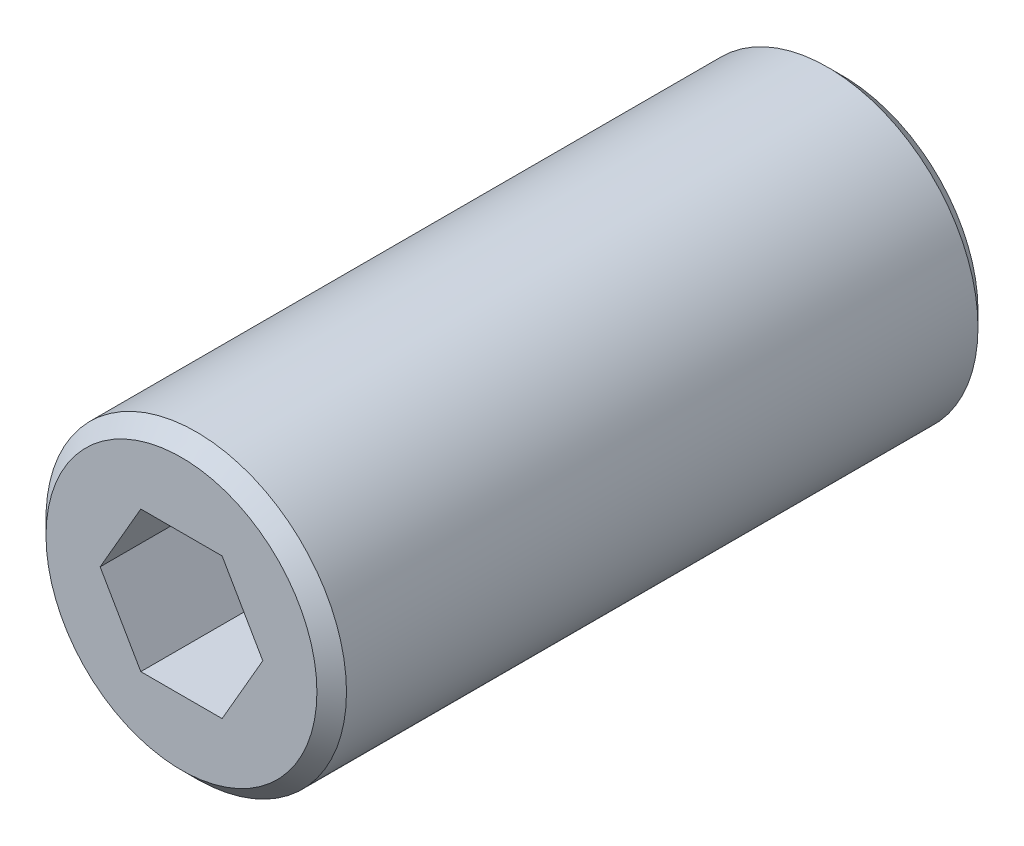
from build123d import *

# Parameters (mm, degrees)
SKETCH1_R           = 10.16
BOSS_EXTRUDE1_DEPTH = 44.704
CHAMFER1_SIZE       = 1


with BuildPart() as part:
    # Sketch1 → Boss-Extrude1 (new body)
    with BuildSketch(Plane.XY):
        Circle(SKETCH1_R)
        Polygon((5.499261314, 0), (2.749630657, 4.7625), (-2.749630657, 4.7625), (-5.499261314, 0), (-2.749630657, -4.7625), (2.749630657, -4.7625), align=None, mode=Mode.SUBTRACT)
    extrude(amount=BOSS_EXTRUDE1_DEPTH)

    # Chamfer1
    chamfer1_edges = [part.edges().sort_by_distance(p)[0] for p in [
        (-10.16, 0, 0),
        (-10.16, 0, 44.704),
    ]]
    chamfer(chamfer1_edges, length=CHAMFER1_SIZE)


solid = part.part
